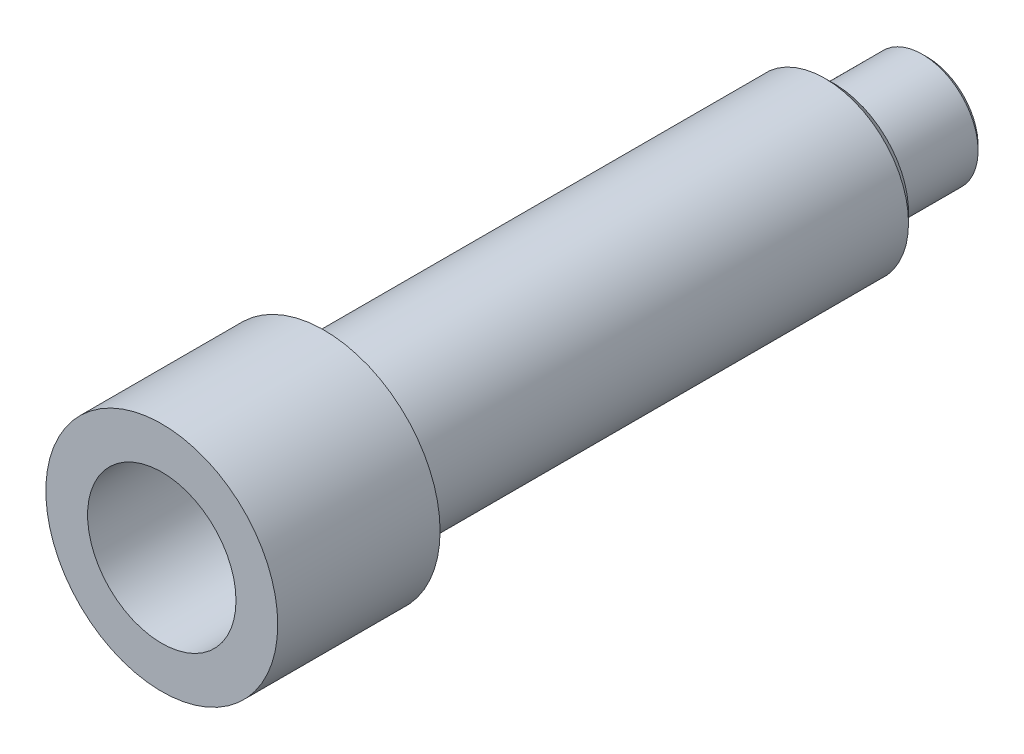
from build123d import *

# Parameters (mm, degrees)
SKETCH_1_R          = 12.5
EXTRUDE_1_DEPTH     = 17.5
SKETCH_2_R          = 9
EXTRUDE_2_DEPTH     = 55
SKETCH_3_R          = 6
EXTRUDE_3_DEPTH     = 10
CHAMFER_1_SIZE      = 0.5
SKETCH_4_R          = 5
CUT_EXTRUDE_1_DEPTH = 139
CHAMFER_2_SIZE      = 1
SKETCH_5_R          = 8
CUT_EXTRUDE_2_DEPTH = 12


with BuildPart() as part:
    # 草图1 → 凸台-拉伸1 (new body)
    with BuildSketch(Plane.XY):
        Circle(SKETCH_1_R)
    extrude(amount=EXTRUDE_1_DEPTH)

    # 草图2 → 凸台-拉伸2 (add)
    with BuildSketch(Plane(origin=(0, 0, 0), x_dir=(-1, 0, 0), z_dir=(0, 0, -1))):
        Circle(SKETCH_2_R)
    extrude(amount=EXTRUDE_2_DEPTH)

    # 草图3 → 凸台-拉伸3 (add)
    with BuildSketch(Plane(origin=(0, 0, -55), x_dir=(-1, 0, 0), z_dir=(0, 0, -1))):
        Circle(SKETCH_3_R)
    extrude(amount=EXTRUDE_3_DEPTH)

    # 倒角1
    chamfer_1_edges = [part.edges().sort_by_distance(p)[0] for p in [
        (6, 0, -65),
    ]]
    chamfer(chamfer_1_edges, length=CHAMFER_1_SIZE)

    # 草图4 → 切除-拉伸1 (cut)
    with BuildSketch(Plane(origin=(0, 0, -65), x_dir=(-1, 0, 0), z_dir=(0, 0, -1))):
        Circle(SKETCH_4_R)
    extrude(amount=-CUT_EXTRUDE_1_DEPTH, mode=Mode.SUBTRACT)

    # 倒角2
    chamfer_2_edges = [part.edges().sort_by_distance(p)[0] for p in [
        (9, 0, -55),
    ]]
    chamfer(chamfer_2_edges, length=CHAMFER_2_SIZE)

    # 草图5 → 切除-拉伸2 (cut)
    with BuildSketch(Plane.XY.offset(17.5)):
        Circle(SKETCH_5_R)
    extrude(amount=-CUT_EXTRUDE_2_DEPTH, mode=Mode.SUBTRACT)


solid = part.part
